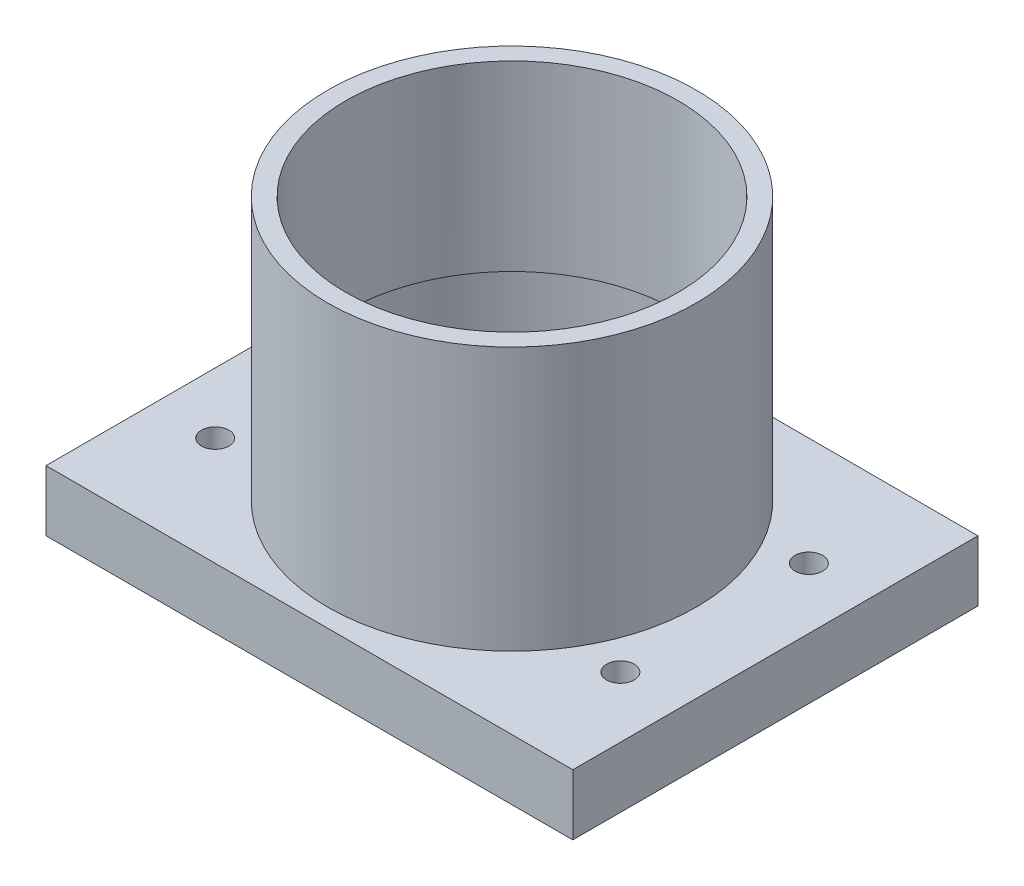
from build123d import *

# Parameters (mm, degrees)
SKETCH1_W             = 130
SKETCH1_H             = 100
BOSS_EXTRUDE1_DEPTH   = 15
SKETCH2_R             = 45.5
BOSS_EXTRUDE2_DEPTH   = 65
SKETCH3_R             = 41
CUT_EXTRUDE1_DEPTH    = 81
SKETCH4_R             = 42.5
CUT_EXTRUDE2_DEPTH    = 35
M8_TAPPED_HOLE1_D     = 6.8
M8_TAPPED_HOLE1_DEPTH = 17.707073895
M8_TAPPED_HOLE1_TIP   = 2.042926105


with BuildPart() as part:
    # Sketch1 → Boss-Extrude1 (new body)
    with BuildSketch(Plane(origin=(0, 0, 0), x_dir=(1, 0, 0), z_dir=(0, 1, 0))):
        Rectangle(SKETCH1_W, SKETCH1_H)
    extrude(amount=BOSS_EXTRUDE1_DEPTH)

    # Sketch2 → Boss-Extrude2 (add)
    with BuildSketch(Plane(origin=(0, 15, 0), x_dir=(1, 0, 0), z_dir=(0, 1, 0))):
        Circle(SKETCH2_R)
    extrude(amount=BOSS_EXTRUDE2_DEPTH)

    # Sketch3 → Cut-Extrude1 (cut, through all)
    with BuildSketch(Plane(origin=(0, 80, 0), x_dir=(1, 0, 0), z_dir=(0, 1, 0))):
        Circle(SKETCH3_R)
    extrude(amount=-CUT_EXTRUDE1_DEPTH, mode=Mode.SUBTRACT)

    # Sketch4 → Cut-Extrude2 (cut)
    with BuildSketch(Plane.XZ):
        Circle(SKETCH4_R)
    extrude(amount=-CUT_EXTRUDE2_DEPTH, mode=Mode.SUBTRACT)

    # M8 Tapped Hole1
    with Locations(Plane(origin=(0, 15, 0), x_dir=(1, 0, 0), z_dir=(0, 1, 0))):
        with Locations((-50, 23.25), (-50, -23.25), (50, -23.25), (50, 23.25)):
            Hole(M8_TAPPED_HOLE1_D / 2, depth=M8_TAPPED_HOLE1_DEPTH)
            with Locations((0, 0, -(M8_TAPPED_HOLE1_DEPTH + M8_TAPPED_HOLE1_TIP / 2))):  # 118° drill point
                Cone(0, M8_TAPPED_HOLE1_D / 2, M8_TAPPED_HOLE1_TIP, mode=Mode.SUBTRACT)


solid = part.part
